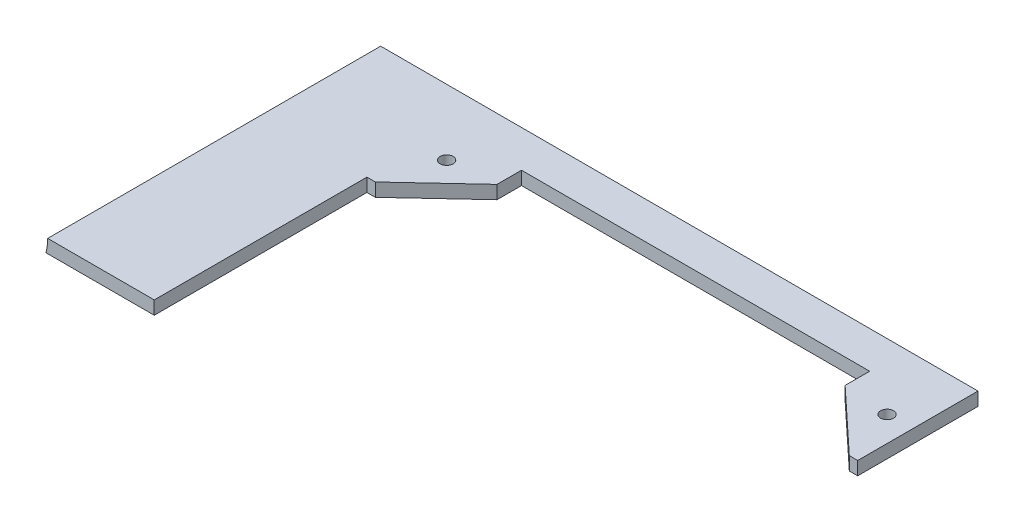
from build123d import *

# Parameters (mm, degrees)
SKETCH1_W            = 190.5
SKETCH1_H            = 76.2
BOSS_EXTRUDE1_DEPTH  = 3.175
SKETCH2_R            = 1.545336663
CUT_EXTRUDE4_DEPTH   = 4.175
SKETCH3_W            = 153.75
SKETCH3_H            = 3.175
BOSS_EXTRUDE2_DEPTH  = 3.175
CUT_SWEEP1_PROFILE_R = 12.7


with BuildPart() as part:
    # Sketch1 → Boss-Extrude1 (new body)
    with BuildSketch(Plane(origin=(0, 0, 0), x_dir=(1, 0, 0), z_dir=(0, 1, 0))):
        Rectangle(SKETCH1_W, SKETCH1_H)
    extrude(amount=BOSS_EXTRUDE1_DEPTH)

    # Sketch2 → Cut-Extrude4 (cut, through all)
    with BuildSketch(Plane(origin=(0, 3.175, 0), x_dir=(1, 0, 0), z_dir=(0, 1, 0))):
        Polygon((-58.5, 12.6), (-58.5, -38.1), (95.25, -38.1), (95.25, 38.1), (58.5, 38.1), (58.5, 12.6), (56.5, 12.6), (41.5, 26.6), (41.5, 32.45), (-41.5, 32.45), (-41.5, 26.6), (-56.5, 12.6), align=None)
        with Locations((-52.505245516, 25.605245516)):
            Circle(SKETCH2_R)
        with Locations((52.5, 25.605245516)):
            Circle(SKETCH2_R)
    extrude(amount=-CUT_EXTRUDE4_DEPTH, mode=Mode.SUBTRACT)

    # Sketch3 → Boss-Extrude2 (add)
    with BuildSketch(Plane(origin=(0, 0, -38.1), x_dir=(-1, 0, 0), z_dir=(0, 0, -1))):
        with Locations((18.375, 1.5875)):
            Rectangle(SKETCH3_W, SKETCH3_H)
    extrude(amount=BOSS_EXTRUDE2_DEPTH)

    # Cut-Sweep1: sweep along a curve in space
    with BuildLine() as cut_sweep1_path:
        Line((-96.6, 3.175, 467.883912637), (-96.6, 3.175, -36.654630794))
        Line((-96.6, 3.175, -36.654630794), (-96.6, 3.175, -207.159673584))
    # Cut-Sweep1 profile (on start of the path) → Cut-Sweep1 (sweep, cut)
    with BuildSketch(Plane(origin=(-96.6, 3.175, 467.883912637), x_dir=(0, -1, 0), z_dir=(0, 0, -1))):
        Circle(CUT_SWEEP1_PROFILE_R)
    sweep(path=cut_sweep1_path.line, mode=Mode.SUBTRACT)


solid = part.part
